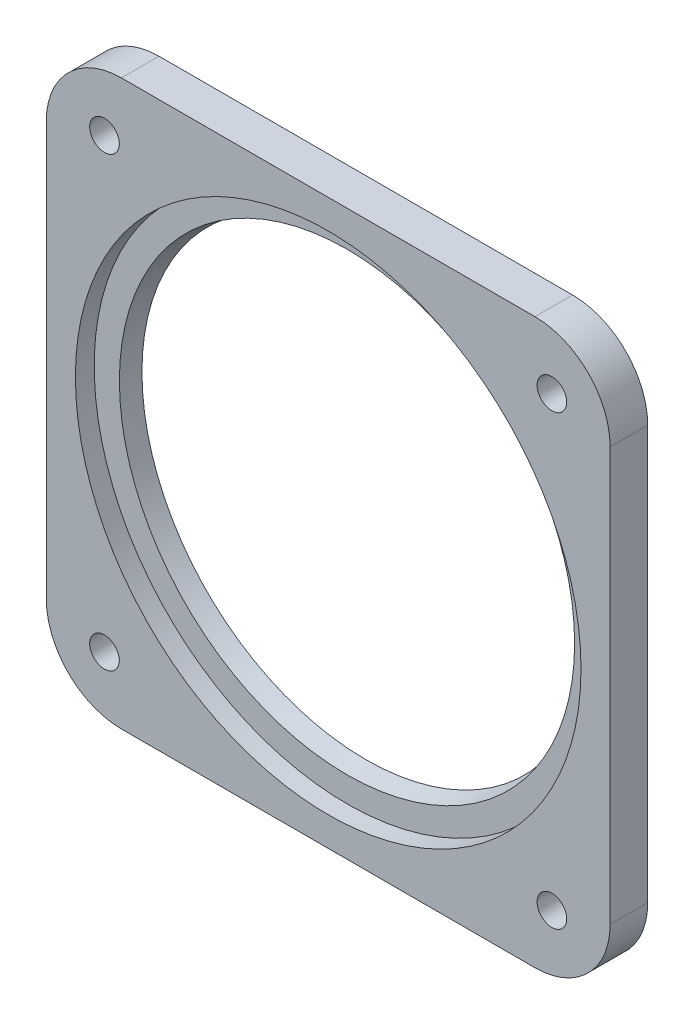
from build123d import *

# Parameters (mm, degrees)
SKETCH1_R                              = 76.8985
BOSS_EXTRUDE1_DEPTH                    = 12.7
INSET_START                            = 25.4
SKETCH4_R                              = 85.4075
SKETCH4_R_2                            = 76.2
INSET_RIM_DEPTH                        = 19.05
CBORE_FOR_M8_HEX_HEAD_BOLT1_AT_2_COUNT = 2
CBORE_FOR_M8_HEX_HEAD_BOLT1_AT_2_PITCH = 213.781317332
CBORE_FOR_M8_HEX_HEAD_BOLT1_AT_3_COUNT = 2
CBORE_FOR_M8_HEX_HEAD_BOLT1_AT_3_PITCH = 151.166219176
CBORE_FOR_M8_HEX_HEAD_BOLT1_AT_4_COUNT = 2
CBORE_FOR_M8_HEX_HEAD_BOLT1_AT_4_PITCH = 151.166219176


with BuildPart() as part:
    # Sketch1 → Boss-Extrude1 (new body)
    with BuildSketch(Plane.XY):
        with BuildLine():
            Line((95.25, 69.85), (95.25, -69.85))
            ThreePointArc((95.25, -69.85), (87.810512242, -87.810512242), (69.85, -95.25))
            Line((69.85, -95.25), (-69.85, -95.25))
            ThreePointArc((-69.85, -95.25), (-87.810512242, -87.810512242), (-95.25, -69.85))
            Line((-95.25, -69.85), (-95.25, 69.85))
            ThreePointArc((-95.25, 69.85), (-87.810512242, 87.810512242), (-69.85, 95.25))
            Line((-69.85, 95.25), (69.85, 95.25))
            ThreePointArc((69.85, 95.25), (87.810512242, 87.810512242), (95.25, 69.85))
        make_face()
        Circle(SKETCH1_R, mode=Mode.SUBTRACT)
    extrude(amount=BOSS_EXTRUDE1_DEPTH)

    # Sketch4 → Inset Rim (cut)
    with BuildSketch(Plane.XY.offset(INSET_START)):
        Circle(SKETCH4_R)
        Circle(SKETCH4_R_2, mode=Mode.SUBTRACT)
    extrude(amount=-INSET_RIM_DEPTH, mode=Mode.SUBTRACT)

    # Sketch8 → CBORE for M8 Hex Head Bolt1 (revolve, cut)
    with BuildSketch(Plane(origin=(-75.583109588, -75.583109588, 0), x_dir=(0, 1, 0), z_dir=(1, 0, 0))):
        Polygon((0, 0), (0, 12.7), (5, 12.7), (5, 5.3), (9.0055, 5.3), (9.0055, 0), align=None)
    cbore_for_m8_hex_head_bolt1 = revolve(axis=Axis((-75.583109588, -75.583109588, -6.35), (0, 0, 1)), mode=Mode.SUBTRACT)

    # CBORE for M8 Hex Head Bolt1 at 2: CBORE for M8 Hex Head Bolt1 ×2
    with Locations(*[Vector(0.707106781, 0.707106781, 0) * (i * CBORE_FOR_M8_HEX_HEAD_BOLT1_AT_2_PITCH) for i in range(1, CBORE_FOR_M8_HEX_HEAD_BOLT1_AT_2_COUNT)]):
        add(cbore_for_m8_hex_head_bolt1, mode=Mode.SUBTRACT)

    # CBORE for M8 Hex Head Bolt1 at 3: CBORE for M8 Hex Head Bolt1 ×2
    with Locations(*[(0, i * CBORE_FOR_M8_HEX_HEAD_BOLT1_AT_3_PITCH, 0) for i in range(1, CBORE_FOR_M8_HEX_HEAD_BOLT1_AT_3_COUNT)]):
        add(cbore_for_m8_hex_head_bolt1, mode=Mode.SUBTRACT)

    # CBORE for M8 Hex Head Bolt1 at 4: CBORE for M8 Hex Head Bolt1 ×2
    with Locations(*[(i * CBORE_FOR_M8_HEX_HEAD_BOLT1_AT_4_PITCH, 0, 0) for i in range(1, CBORE_FOR_M8_HEX_HEAD_BOLT1_AT_4_COUNT)]):
        add(cbore_for_m8_hex_head_bolt1, mode=Mode.SUBTRACT)


with BuildPart() as body_2:
    # Sketch6 → Revolve1 (revolve)
    with BuildSketch(Plane(origin=(0, 0, 0), x_dir=(1, 0, 0), z_dir=(0, 1, 0))):
        Polygon((-76.8985, 0), (-76.8985, -6.35), (-75.6285, 0), align=None)
    revolve(axis=Axis((0, 0, -10.998218641), (0, 0, 1)))


solid = Compound([part.part, body_2.part])
